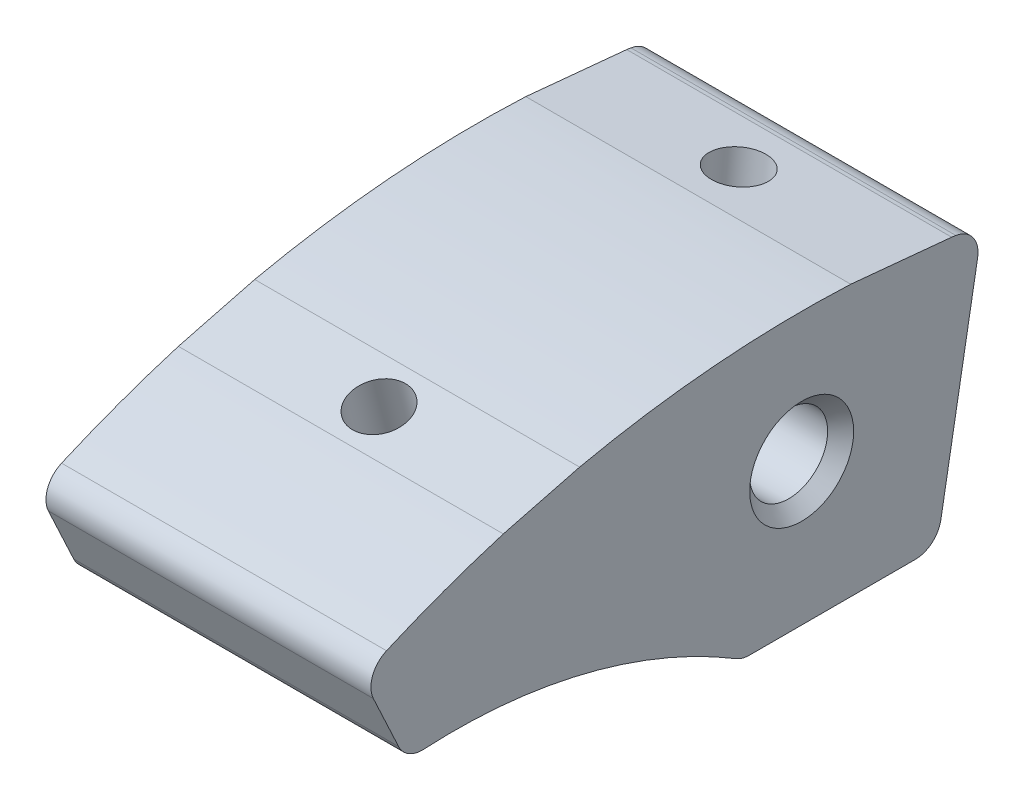
from build123d import *

# Parameters (mm, degrees)
SKETCH1_R             = 3
BOSS_EXTRUDE1_DEPTH   = 25
FILLET2_R             = 2
CUT_EXTRUDE1_DEPTH    = 26
M5_TAPPED_HOLE1_D     = 4.2
M5_TAPPED_HOLE1_DEPTH = 22.4
M5_TAPPED_HOLE1_TIP   = 1.2618073
M5_TAPPED_HOLE2_D     = 4.2
M5_TAPPED_HOLE2_DEPTH = 22.4
M5_TAPPED_HOLE2_TIP   = 1.2618073
M4_TAPPED_HOLE1_D     = 3.3
M4_TAPPED_HOLE1_DEPTH = 10.1
M4_TAPPED_HOLE1_TIP   = 0.991420021
CHAMFER1_SIZE         = 1


with BuildPart() as part:
    # Sketch1 → Boss-Extrude1 (new body)
    with BuildSketch(Plane(origin=(0, 0, 0), x_dir=(0, 0, -1), z_dir=(1, 0, 0))):
        with BuildLine():
            Line((-33.809460939, 72.504622963), (-30.428514845, 65.254160667))
            ThreePointArc((-30.428514845, 65.254160667), (-17.004346403, 64.269330845), (-4.58110934, 59.088465181))
            Line((-4.58110934, 59.088465181), (10.41889066, 59.088465181))
            Line((10.41889066, 59.088465181), (13.891854213, 78.784620241))
            ThreePointArc((13.891854213, 78.784620241), (-10.442095378, 79.31558891), (-33.809460939, 72.504622963))
        make_face()
        with Locations((0, 70)):
            Circle(SKETCH1_R, mode=Mode.SUBTRACT)
    extrude(amount=BOSS_EXTRUDE1_DEPTH)

    # Fillet2
    fillet2_edges = [part.edges().sort_by_distance(p)[0] for p in [
        (12.5, 59.088465181, 4.58110934),
        (12.5, 65.254160667, 30.428514845),
        (12.5, 72.504622963, 33.809460939),
        (12.5, 78.784620241, -13.891854213),
        (12.5, 59.088465181, -10.41889066),
    ]]
    fillet(fillet2_edges, radius=FILLET2_R)

    # Sketch3 → Cut-Extrude1 (cut, through all)
    with BuildSketch(Plane(origin=(25, 0, 0), x_dir=(0, 0, -1), z_dir=(1, 0, 0))):
        Polygon((-23.953386268, 80.509473559), (-18.081663619, 82.028004286), (-17.080143603, 78.155413725), (-22.951866252, 76.636882997), align=None)
        Polygon((3.776986852, 89.910790074), (11.540104609, 89.163286855), (11.540104609, 79.163286855), (3.776986852, 79.910790074), align=None)
    extrude(amount=-CUT_EXTRUDE1_DEPTH, mode=Mode.SUBTRACT)

    # M5 Tapped Hole1
    with Locations(Plane(origin=(0, 77.396148361, 20.016004928), x_dir=(1, 0, 0), z_dir=(0, 0.96814764, 0.250380004))):
        with Locations((12.5, 0)):
            Hole(M5_TAPPED_HOLE1_D / 2, depth=M5_TAPPED_HOLE1_DEPTH)
            with Locations((0, 0, -(M5_TAPPED_HOLE1_DEPTH + M5_TAPPED_HOLE1_TIP / 2))):  # 118° drill point
                Cone(0, M5_TAPPED_HOLE1_D / 2, M5_TAPPED_HOLE1_TIP, mode=Mode.SUBTRACT)

    # M5 Tapped Hole2
    with Locations(Plane(origin=(0, 79.537038465, -7.65854573), x_dir=(1, 0, 0), z_dir=(0, 0.995396198, -0.095845753))):
        with Locations((12.5, 0)):
            Hole(M5_TAPPED_HOLE2_D / 2, depth=M5_TAPPED_HOLE2_DEPTH)
            with Locations((0, 0, -(M5_TAPPED_HOLE2_DEPTH + M5_TAPPED_HOLE2_TIP / 2))):  # 118° drill point
                Cone(0, M5_TAPPED_HOLE2_D / 2, M5_TAPPED_HOLE2_TIP, mode=Mode.SUBTRACT)

    # M4 Tapped Hole1
    with Locations(Plane(origin=(0, 59.088465181, 0), x_dir=(-1, 0, 0), z_dir=(0, -1, 0))):
        with Locations((-6.5, 0), (-18.5, 0)):
            Hole(M4_TAPPED_HOLE1_D / 2, depth=M4_TAPPED_HOLE1_DEPTH)
            with Locations((0, 0, -(M4_TAPPED_HOLE1_DEPTH + M4_TAPPED_HOLE1_TIP / 2))):  # 118° drill point
                Cone(0, M4_TAPPED_HOLE1_D / 2, M4_TAPPED_HOLE1_TIP, mode=Mode.SUBTRACT)

    # Chamfer1
    chamfer1_edges = [part.edges().sort_by_distance(p)[0] for p in [
        (25, 70, 3),
        (0, 70, 3),
    ]]
    chamfer(chamfer1_edges, length=CHAMFER1_SIZE)


solid = part.part
